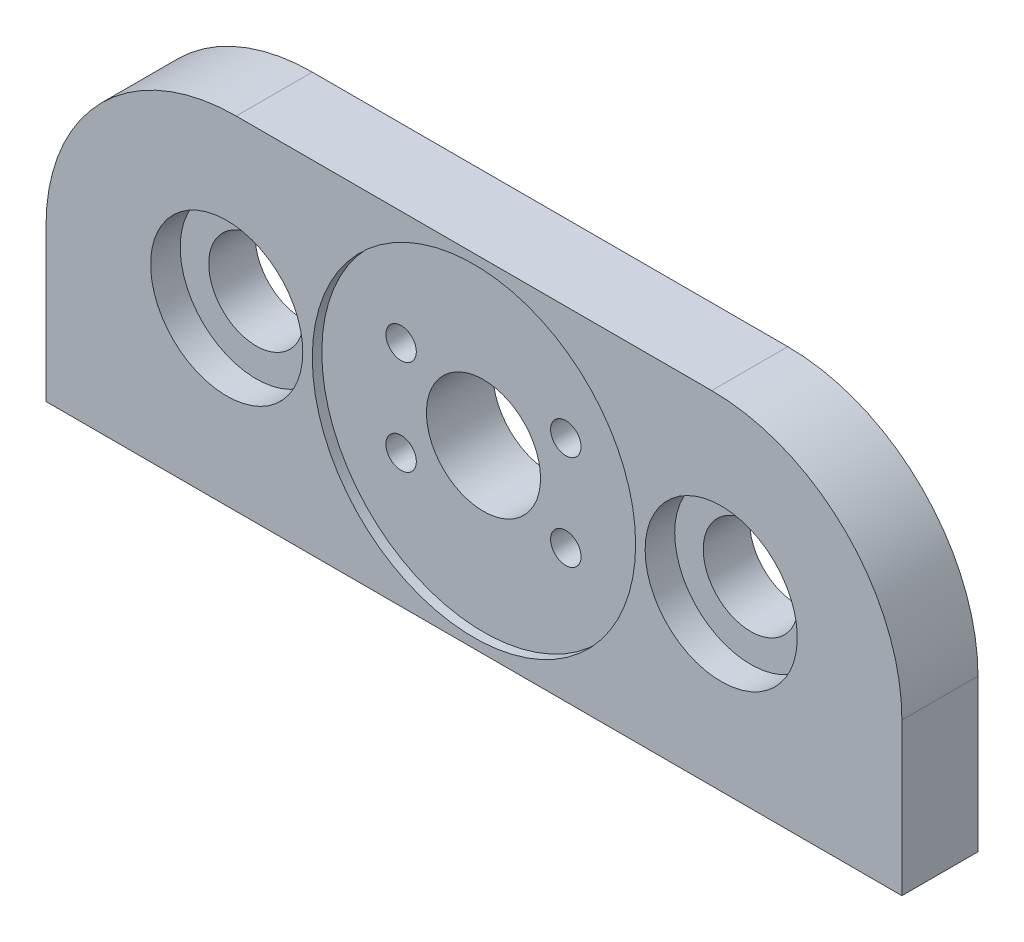
from build123d import *

# Parameters (mm, degrees)
SKETCH1_W           = 45
SKETCH1_H           = 4
BOSS_EXTRUDE1_DEPTH = 18
SKETCH2_R           = 8.5
CUT_EXTRUDE2_DEPTH  = 0.5
SKETCH3_R           = 3
CUT_EXTRUDE3_DEPTH  = 4.5
SKETCH4_R           = 2.5
CUT_EXTRUDE4_DEPTH  = 5
SKETCH6_R           = 0.8
CUT_EXTRUDE6_DEPTH  = 4.5
FILLET1_R           = 10
SKETCH7_R           = 4
CUT_EXTRUDE7_DEPTH  = 1.555
CUT_EXTRUDE8_DEPTH  = 1.3
SKETCH9_R           = 0.9
CUT_EXTRUDE9_DEPTH  = 5
SKETCH10_R          = 0.9
CUT_EXTRUDE10_DEPTH = 5
CHAMFER1_SIZE       = 0.7


with BuildPart() as part:
    # Sketch1 → Boss-Extrude1 (new body)
    with BuildSketch(Plane(origin=(0, 0, 0), x_dir=(1, 0, 0), z_dir=(0, 1, 0))):
        with Locations((-22.5, 2)):
            Rectangle(SKETCH1_W, SKETCH1_H)
    extrude(amount=BOSS_EXTRUDE1_DEPTH)

    # Sketch2 → Cut-Extrude2 (cut)
    with BuildSketch(Plane.XY):
        with Locations((-22.5, 9)):
            Circle(SKETCH2_R)
    extrude(amount=-CUT_EXTRUDE2_DEPTH, mode=Mode.SUBTRACT)

    # Sketch3 → Cut-Extrude3 (cut, through all)
    with BuildSketch(Plane.XY.offset(-0.5)):
        with Locations((-22.5, 9)):
            Circle(SKETCH3_R)
    extrude(amount=-CUT_EXTRUDE3_DEPTH, mode=Mode.SUBTRACT)

    # Sketch4 → Cut-Extrude4 (cut, through all)
    with BuildSketch(Plane.XY):
        with Locations((-35.5, 9)):
            Circle(SKETCH4_R)
        with Locations((-9.5, 9)):
            Circle(SKETCH4_R)
    extrude(amount=-CUT_EXTRUDE4_DEPTH, mode=Mode.SUBTRACT)

    # Sketch6 → Cut-Extrude6 (cut, through all)
    with BuildSketch(Plane.XY.offset(-0.5)):
        with Locations((-18.169872981, 11.5)):
            Circle(SKETCH6_R)
        with Locations((-18.169872981, 6.5)):
            Circle(SKETCH6_R)
        with Locations((-26.830127019, 6.5)):
            Circle(SKETCH6_R)
        with Locations((-26.830127019, 11.5)):
            Circle(SKETCH6_R)
    extrude(amount=-CUT_EXTRUDE6_DEPTH, mode=Mode.SUBTRACT)

    # Fillet1
    fillet1_edges = [part.edges().sort_by_distance(p)[0] for p in [
        (-45, 18, -2),
        (0, 18, -2),
    ]]
    fillet(fillet1_edges, radius=FILLET1_R)

    # Sketch7 → Cut-Extrude7 (cut)
    with BuildSketch(Plane.XY):
        with Locations((-35.5, 9)):
            Circle(SKETCH7_R)
        with Locations((-9.5, 9)):
            Circle(SKETCH7_R)
    extrude(amount=-CUT_EXTRUDE7_DEPTH, mode=Mode.SUBTRACT)

    # Sketch8 → Cut-Extrude8 (cut)
    with BuildSketch(Plane.XZ):
        Polygon((-5.217293911, -2), (-4.417293911, -0.614359354), (-2.817293911, -0.614359354), (-2.017293911, -2), (-2.817293911, -3.385640646), (-4.417293911, -3.385640646), align=None)
        Polygon((-39.782706089, -2), (-40.582706089, -0.614359354), (-42.182706089, -0.614359354), (-42.982706089, -2), (-42.182706089, -3.385640646), (-40.582706089, -3.385640646), align=None)
    extrude(amount=-CUT_EXTRUDE8_DEPTH, mode=Mode.SUBTRACT)

    # Sketch9 → Cut-Extrude9 (cut)
    with BuildSketch(Plane.XZ.offset(-1.3)):
        with Locations((-41.382706089, -2)):
            Circle(SKETCH9_R)
    extrude(amount=-CUT_EXTRUDE9_DEPTH, mode=Mode.SUBTRACT)

    # Sketch10 → Cut-Extrude10 (cut)
    with BuildSketch(Plane.XZ.offset(-1.3)):
        with Locations((-3.617293911, -2)):
            Circle(SKETCH10_R)
    extrude(amount=-CUT_EXTRUDE10_DEPTH, mode=Mode.SUBTRACT)

    # Chamfer1
    chamfer1_edges = [part.edges().sort_by_distance(p)[0] for p in [
        (-27.630127019, 11.5, -4),
        (-18.969872981, 11.5, -4),
        (-18.969872981, 6.5, -4),
        (-27.630127019, 6.5, -4),
    ]]
    chamfer(chamfer1_edges, length=CHAMFER1_SIZE)


solid = part.part
